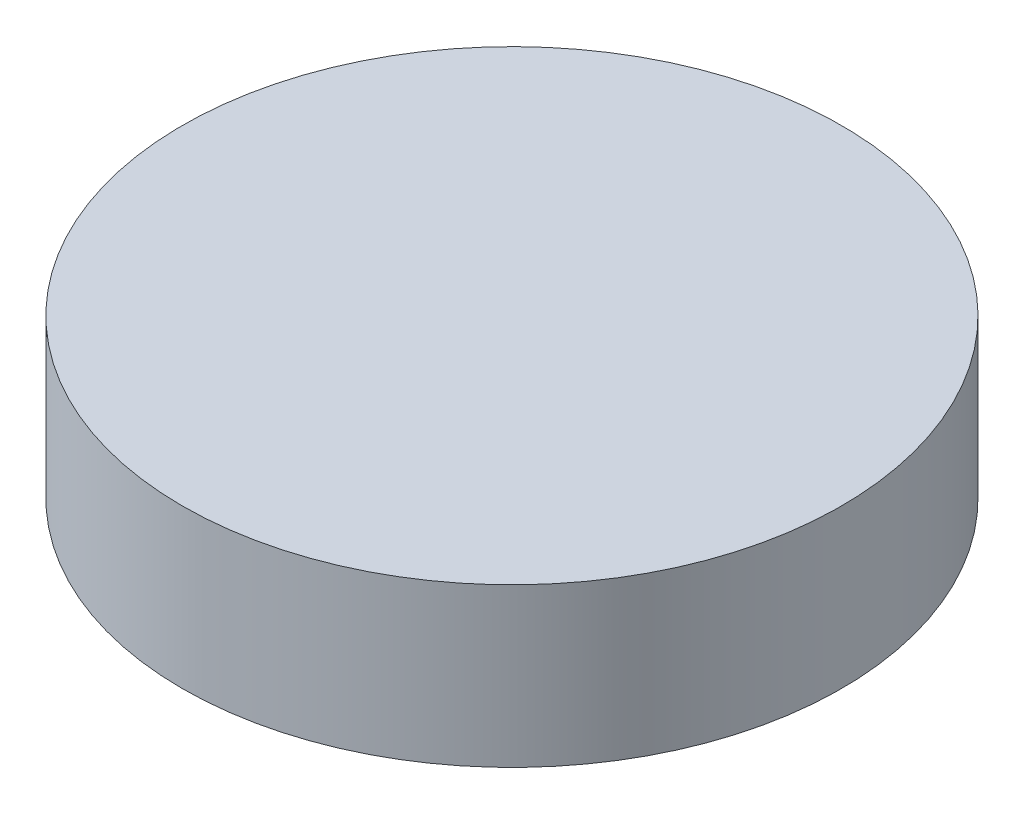
from build123d import *

# Parameters (mm, degrees)
SKETCH2_R           = 12.5
BOSS_EXTRUDE1_DEPTH = 3
SKETCH4_R           = 3
CUT_EXTRUDE2_DEPTH  = 3


with BuildPart() as part:
    # Sketch2 → Boss-Extrude1 (new body, symmetric)
    with BuildSketch(Plane(origin=(0, 0, 0), x_dir=(1, 0, 0), z_dir=(0, 1, 0))):
        Circle(SKETCH2_R)
    extrude(amount=BOSS_EXTRUDE1_DEPTH, both=True)

    # Sketch4 → Cut-Extrude2 (cut)
    with BuildSketch(Plane(origin=(0, -3, 0), x_dir=(-1, 0, 0), z_dir=(0, -1, 0))):
        Circle(SKETCH4_R)
    extrude(amount=-CUT_EXTRUDE2_DEPTH, mode=Mode.SUBTRACT)


solid = part.part
